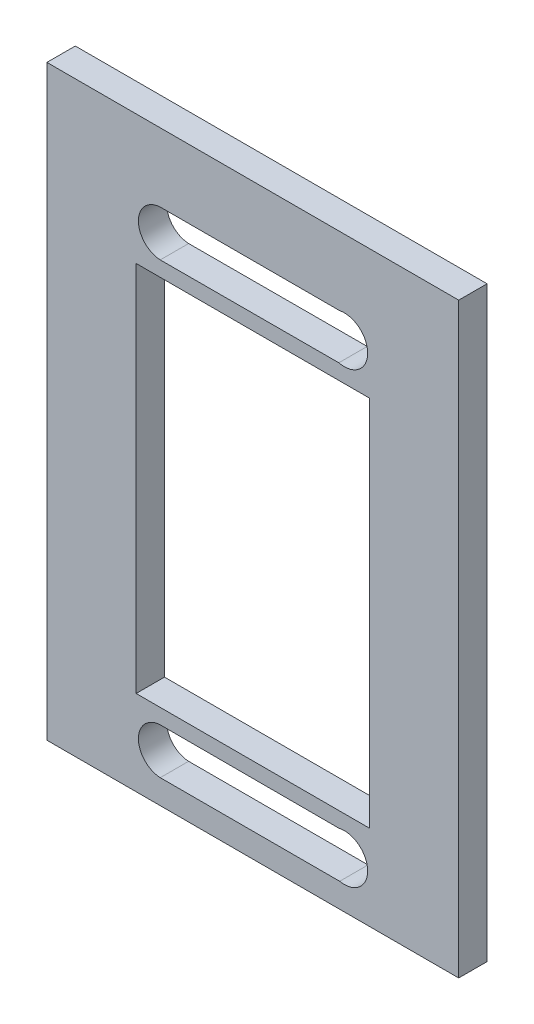
from build123d import *

# Parameters (mm, degrees)
SKETCH1_W           = 45
SKETCH1_H           = 80
SKETCH1_W_2         = 25.5
SKETCH1_H_2         = 40.7
BOSS_EXTRUDE1_DEPTH = 3.1
SKETCH8_W           = 45
SKETCH8_H           = 15.85
CUT_EXTRUDE4_DEPTH  = 4.1


with BuildPart() as part:
    # Sketch1 → Boss-Extrude1 (new body)
    with BuildSketch(Plane.XY):
        Rectangle(SKETCH1_W, SKETCH1_H)
        with Locations((0, -10.35)):
            Rectangle(SKETCH1_W_2, SKETCH1_H_2, mode=Mode.SUBTRACT)
        with BuildLine():
            Line((-10.115047428, 16.65), (9.493300094, 16.65))
            ThreePointArc((9.493300094, 16.65), (12.550371011, 14.101497401), (9.398611565, 11.671073469))
            Line((9.398611565, 11.671073469), (-10.115047428, 11.65))
            ThreePointArc((-10.115047428, 11.65), (-12.502645782, 14.15), (-10.115047428, 16.65))
        make_face(mode=Mode.SUBTRACT)
        with BuildLine():
            Line((-10.115047428, -32.35), (9.398611565, -32.371073469))
            ThreePointArc((9.398611565, -32.371073469), (12.550371011, -34.801497401), (9.493300094, -37.35))
            Line((9.493300094, -37.35), (-10.115047428, -37.35))
            ThreePointArc((-10.115047428, -37.35), (-12.502645782, -34.85), (-10.115047428, -32.35))
        make_face(mode=Mode.SUBTRACT)
    extrude(amount=BOSS_EXTRUDE1_DEPTH)

    # Sketch8 → Cut-Extrude4 (cut, through all)
    with BuildSketch(Plane.XY.offset(3.1)):
        with Locations((0, 32.075)):
            Rectangle(SKETCH8_W, SKETCH8_H)
    extrude(amount=-CUT_EXTRUDE4_DEPTH, mode=Mode.SUBTRACT)


solid = part.part
